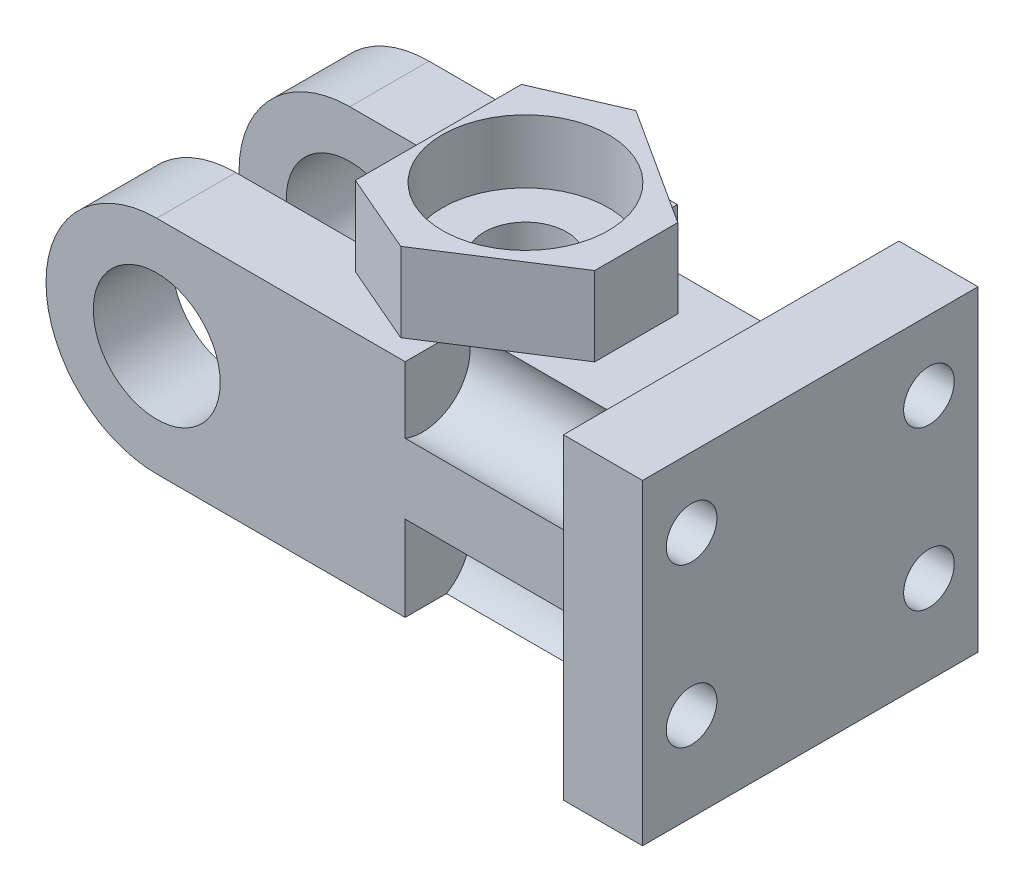
from build123d import *

# Parameters (mm, degrees)
SKETCH_1_R          = 4.01
EXTRUDE_1_DEPTH     = 17.2
SKETCH_2_W          = 16.2
SKETCH_2_H          = 7.2
CUT_EXTRUDE_1_DEPTH = 18
SKETCH_4_W          = 2
SKETCH_4_H          = 20
EXTRUDE_2_DEPTH     = 5
SKETCH_3_R          = 1.6
CUT_EXTRUDE_2_DEPTH = 5
CUT_EXTRUDE_START   = -5
SKETCH_5_R          = 3
CUT_EXTRUDE_3_DEPTH = 12
EXTRUDE_7_DEPTH     = 5
SKETCH_7_R          = 5.25
CUT_EXTRUDE_8_DEPTH = 4
CUT_EXTRUDE_9_REACH = 20
SKETCH_8_R          = 2.6


with BuildPart() as part:
    # ｽｹｯﾁ1 → ﾎﾞｽ - 押し出し1 (new body)
    with BuildSketch(Plane.XY):
        with BuildLine():
            Line((24, 53), (51.7, 53))
            Line((51.7, 53), (51.7, 56))
            Line((51.7, 56), (56.7, 56))
            Line((56.7, 56), (56.7, 36))
            Line((56.7, 36), (51.7, 36))
            Line((51.7, 36), (51.7, 39))
            Line((51.7, 39), (24, 39))
            ThreePointArc((24, 39), (17, 46), (24, 53))
        make_face()
        with Locations((24, 46)):
            Circle(SKETCH_1_R, mode=Mode.SUBTRACT)
    extrude(amount=EXTRUDE_1_DEPTH)

    # ｽｹｯﾁ2 → ｶｯﾄ - 押し出し1 (cut, through all)
    with BuildSketch(Plane(origin=(0, 53, 0), x_dir=(1, 0, 0), z_dir=(0, 1, 0))):
        with Locations((25.1, -8.6)):
            Rectangle(SKETCH_2_W, SKETCH_2_H)
    extrude(amount=-CUT_EXTRUDE_1_DEPTH, mode=Mode.SUBTRACT)

    # ｽｹｯﾁ4 → ﾎﾞｽ - 押し出し2 (add)
    with BuildSketch(Plane(origin=(56.7, 0, 0), x_dir=(0, 0, -1), z_dir=(1, 0, 0))):
        with Locations((-18.2, 46)):
            Rectangle(SKETCH_4_W, SKETCH_4_H)
        with Locations((1, 46)):
            Rectangle(SKETCH_4_W, SKETCH_4_H)
    extrude(amount=-EXTRUDE_2_DEPTH)

    # ｽｹｯﾁ3 → ｶｯﾄ - 押し出し2 (cut)
    with BuildSketch(Plane(origin=(56.7, 0, 0), x_dir=(0, 0, -1), z_dir=(1, 0, 0))):
        with Locations((-16.1, 51.592630867)):
            Circle(SKETCH_3_R)
        with Locations((-1.1, 51.592630867)):
            Circle(SKETCH_3_R)
        with Locations((-16.1, 41.592630867)):
            Circle(SKETCH_3_R)
        with Locations((-1.1, 41.592630867)):
            Circle(SKETCH_3_R)
    extrude(amount=-CUT_EXTRUDE_2_DEPTH, mode=Mode.SUBTRACT)

    # ｽｹｯﾁ5 → ｶｯﾄ - 押し出し3 (cut)
    with BuildSketch(Plane(origin=(56.7, 0, 0), x_dir=(0, 0, -1), z_dir=(1, 0, 0)).offset(CUT_EXTRUDE_START)):
        with Locations((-16.1, 51.592630867)):
            Circle(SKETCH_5_R)
        with Locations((-16.1, 41.592630867)):
            Circle(SKETCH_5_R)
        with Locations((-1.1, 51.592630867)):
            Circle(SKETCH_5_R)
        with Locations((-1.1, 41.592630867)):
            Circle(SKETCH_5_R)
    extrude(amount=-CUT_EXTRUDE_3_DEPTH, mode=Mode.SUBTRACT)

    # ｽｹｯﾁ6 → ﾎﾞｽ - 押し出し7 (add)
    with BuildSketch(Plane(origin=(0, 53, 0), x_dir=(1, 0, 0), z_dir=(0, 1, 0))):
        Polygon((33.2, -3.35), (33.2, -13.85), (38.249508532, -16.030014583), (45.7, -11.225178721), (45.7, -5.974821279), (38.249508532, -1.169985417), align=None)
    extrude(amount=EXTRUDE_7_DEPTH)

    # ｽｹｯﾁ7 → ｶｯﾄ - 押し出し8 (cut)
    with BuildSketch(Plane(origin=(0, 58, 0), x_dir=(1, 0, 0), z_dir=(0, 1, 0))):
        with Locations((38.7, -8.6)):
            Circle(SKETCH_7_R)
    extrude(amount=-CUT_EXTRUDE_8_DEPTH, mode=Mode.SUBTRACT)

    # ｽｹｯﾁ8 → ｶｯﾄ - 押し出し9 (cut, up to next)
    with BuildSketch(Plane(origin=(0, 54, 0), x_dir=(1, 0, 0), z_dir=(0, 1, 0)), mode=Mode.PRIVATE) as cut_extrude_9_sk1:
        with Locations((38.7, -8.6)):
            Circle(SKETCH_8_R)
    cut_extrude_9_tool1 = extrude(cut_extrude_9_sk1.sketch, amount=-CUT_EXTRUDE_9_REACH, mode=Mode.PRIVATE) & part.part
    add(cut_extrude_9_tool1.solids().sort_by_distance((38.7, 54, 8.6))[0], mode=Mode.SUBTRACT)


solid = part.part
